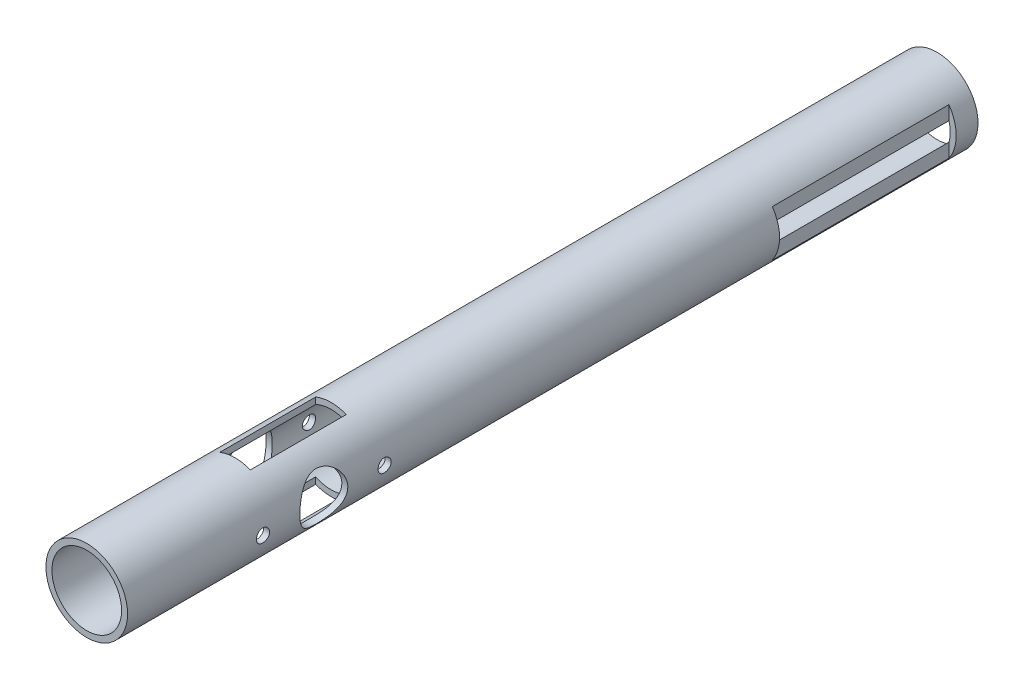
from build123d import *

# Parameters (mm, degrees)
SKETCH1_R           = 9.36
SKETCH1_R_2         = 7.99
EXTRUDE1_DEPTH      = 195
EXTRUDE2_DEPTH      = 196.448763618
EXTRUDE2_DEPTH_BACK = 196.448763618
SKETCH2_R           = 1.5
SKETCH2_R_2         = 5.5
EXTRUDE3_DEPTH      = 25
EXTRUDE3_DEPTH_BACK = 25
SKETCH3_W           = 6.35
SKETCH3_H           = 40.5
SKETCH3_W_2         = 7
SKETCH3_H_2         = 22


with BuildPart() as part:
    # Sketch1 → Extrude1 (new body)
    with BuildSketch(Plane.XY):
        Circle(SKETCH1_R)
        Circle(SKETCH1_R_2, mode=Mode.SUBTRACT)
    extrude(amount=EXTRUDE1_DEPTH)

    # Sketch2 → Extrude2 (cut, two sides: drawn at the far end of the back side and taken through both)
    with BuildSketch(Plane(origin=(0, 0, 0), x_dir=(0, 0, -1), z_dir=(1, 0, 0)).offset(-EXTRUDE2_DEPTH_BACK)):
        with Locations((-30, 0)):
            Circle(SKETCH2_R)
        with Locations((-150, 0)):
            Circle(SKETCH2_R_2)
        with Locations((-136.0625, 0)):
            Circle(SKETCH2_R)
        with Locations((-163.9375, 0)):
            Circle(SKETCH2_R)
    extrude(amount=EXTRUDE2_DEPTH + EXTRUDE2_DEPTH_BACK, mode=Mode.SUBTRACT)

    # Sketch3 → Extrude3 (cut, two sides: drawn at the far end of the back side and taken through both)
    with BuildSketch(Plane(origin=(0, 0, 0), x_dir=(1, 0, 0), z_dir=(0, 1, 0)).offset(-EXTRUDE3_DEPTH_BACK)):
        with Locations((10.875, -25.25)):
            Rectangle(SKETCH3_W, SKETCH3_H)
        with Locations((0, -150)):
            Rectangle(SKETCH3_W_2, SKETCH3_H_2)
    extrude(amount=EXTRUDE3_DEPTH + EXTRUDE3_DEPTH_BACK, mode=Mode.SUBTRACT)


solid = part.part
